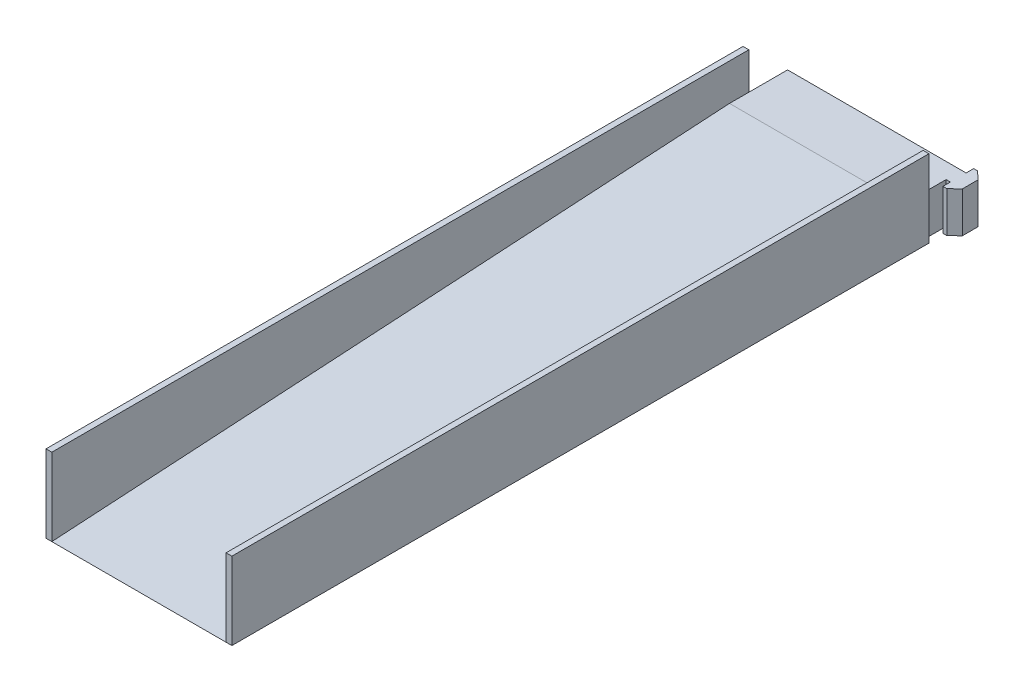
from build123d import *

# Parameters (mm, degrees)
SKETCH1_W           = 90
SKETCH1_H           = 380
SKETCH1_W_2         = 2.2
SKETCH1_H_2         = 8.1
BOSS_EXTRUDE1_DEPTH = 21
CUT_EXTRUDE1_DEPTH  = 99.352414984
SKETCH2_W           = 3
SKETCH2_H           = 360
BOSS_EXTRUDE2_DEPTH = 40


with BuildPart() as part:
    # Sketch1 → Boss-Extrude1 (new body)
    with BuildSketch(Plane(origin=(0, 0, 0), x_dir=(1, 0, 0), z_dir=(0, 1, 0))):
        Rectangle(SKETCH1_W, SKETCH1_H)
        with Locations((46.1, 185.95)):
            Rectangle(SKETCH1_W_2, SKETCH1_H_2)
        Polygon((49.24, 178), (47.2, 178), (47.2, 193.9), (49.24, 193.9), (53.352414984, 189.998), (53.352414984, 181.902), align=None)
    extrude(amount=BOSS_EXTRUDE1_DEPTH)

    # Sketch3 → Cut-Extrude1 (cut, through all)
    with BuildSketch(Plane.ZY.offset(45)):
        Polygon((190, 0), (-160, 21), (190, 21), align=None)
    extrude(amount=-CUT_EXTRUDE1_DEPTH, mode=Mode.SUBTRACT)

    # Sketch2 → Boss-Extrude2 (add)
    with BuildSketch(Plane.XZ):
        with Locations((-46.5, 10)):
            Rectangle(SKETCH2_W, SKETCH2_H)
    boss_extrude2 = extrude(amount=-BOSS_EXTRUDE2_DEPTH)

    # Mirror1: Boss-Extrude2 across plane
    add(boss_extrude2.mirror(Plane(origin=(0, 0, 0), x_dir=(0, 0, 1), z_dir=(1, 0, 0))))


solid = part.part
